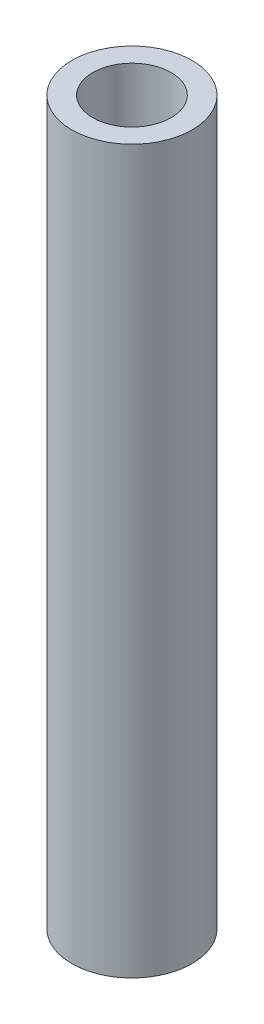
from build123d import *

# Parameters (mm, degrees)
SKETCH1_R           = 4.7625
SKETCH1_R_2         = 3.1
BOSS_EXTRUDE1_DEPTH = 57.15


with BuildPart() as part:
    # Sketch1 → Boss-Extrude1 (new body)
    with BuildSketch(Plane(origin=(0, 0, 0), x_dir=(1, 0, 0), z_dir=(0, 1, 0))):
        Circle(SKETCH1_R)
        Circle(SKETCH1_R_2, mode=Mode.SUBTRACT)
    extrude(amount=BOSS_EXTRUDE1_DEPTH)


solid = part.part
